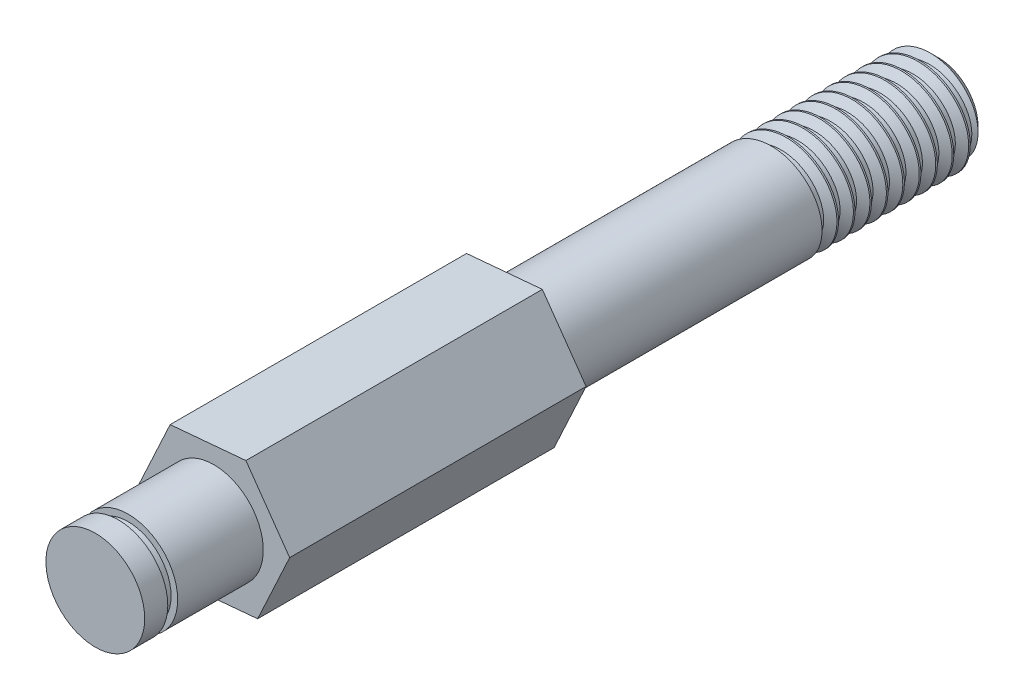
from build123d import *

# Parameters (mm, degrees)
SKETCH_1_R          = 1.5
EXTRUDE_1_DEPTH     = 3.6
EXTRUDE_2_DEPTH     = 9
SKETCH_3_R          = 1.5
EXTRUDE_3_DEPTH     = 13
SKETCH_4_R          = 1.5
SKETCH_4_R_2        = 1.3
CUT_EXTRUDE_1_DEPTH = 0.3
CHAMFER_1_SIZE      = 0.3
SWEEP_1_PITCH       = 0.5
SWEEP_1_HEIGHT      = 5
SWEEP_1_RADIUS      = 1.5
SWEEP_1_START_ANGLE = -180


with BuildPart() as part:
    # 草图1 → 凸台-拉伸1 (new body)
    with BuildSketch(Plane.XY):
        Circle(SKETCH_1_R)
    extrude(amount=EXTRUDE_1_DEPTH)

    # 草图2 → 凸台-拉伸2 (add)
    with BuildSketch(Plane(origin=(0, 0, 0), x_dir=(-1, 0, 0), z_dir=(0, 0, -1))):
        Polygon((2.300200905, -0.205934771), (1.328445196, 1.889065032), (-0.971755709, 2.094999803), (-2.300200905, 0.205934771), (-1.328445196, -1.889065032), (0.971755709, -2.094999803), align=None)
    extrude(amount=EXTRUDE_2_DEPTH)

    # 草图3 → 凸台-拉伸3 (add)
    with BuildSketch(Plane(origin=(0, 0, -9), x_dir=(-1, 0, 0), z_dir=(0, 0, -1))):
        Circle(SKETCH_3_R)
    extrude(amount=EXTRUDE_3_DEPTH)

    # 草图4 → 切除-拉伸1 (cut)
    with BuildSketch(Plane.XY.offset(2.6)):
        with Locations(Location((0, 0, 0), (0, 0, 180))):
            Circle(SKETCH_4_R)
        Circle(SKETCH_4_R_2, mode=Mode.SUBTRACT)
    extrude(amount=CUT_EXTRUDE_1_DEPTH, mode=Mode.SUBTRACT)

    # 倒角1
    chamfer_1_edges = [part.edges().sort_by_distance(p)[0] for p in [
        (1.5, 0, -22),
    ]]
    chamfer(chamfer_1_edges, length=CHAMFER_1_SIZE)

    # 切除-扫描1: sweep along a helix
    with BuildLine() as sweep_1_path:
        add(Helix(SWEEP_1_PITCH, SWEEP_1_HEIGHT, SWEEP_1_RADIUS, center=(0, 0, -22), direction=(0, 0, 1), mode=Mode.PRIVATE).rotate(Axis((0, 0, -22), (0, 0, 1)), SWEEP_1_START_ANGLE))
    # 草图6 → 切除-扫描1 (sweep, cut)
    with BuildSketch(Plane(origin=(0, 0, 0), x_dir=(1, 0, 0), z_dir=(0, 1, 0))):
        Polygon((-1.625246875, 21.638269325), (-1.625246875, 22.238269325), (-1.245246875, 22.013269325), (-1.245246875, 21.863269325), align=None)
    sweep(path=sweep_1_path.line, is_frenet=True, mode=Mode.SUBTRACT)


solid = part.part
